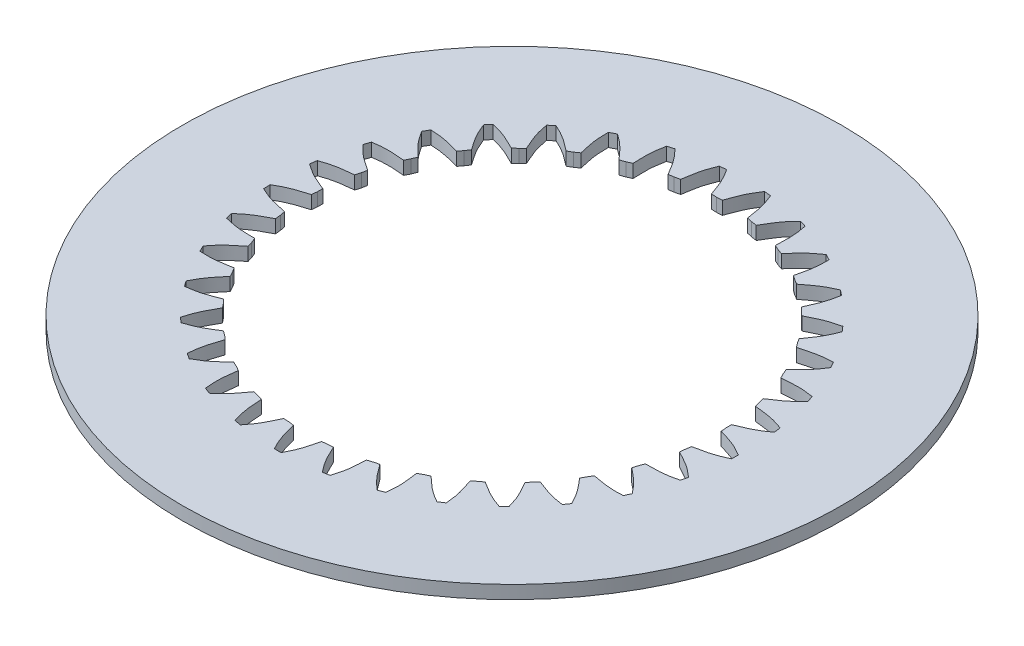
from build123d import *

# Parameters (mm, degrees)
ESBO_O1_R                = 100
RESSALTO_EXTRUS_O2_DEPTH = 4


with BuildPart() as part:
    # Esboço1 → Ressalto-extrusão2 (new body)
    with BuildSketch(Plane(origin=(0, 0, 0), x_dir=(1, 0, 0), z_dir=(0, 1, 0))):
        Circle(ESBO_O1_R)
        with BuildLine():
            Line((-38.387721765, -48.813954903), (-37.138830837, -49.877121184))
            add(Edge.make_bspline(
                [(-37.138830837, -49.877121184), (-37.389257811, -50.639614404), (-37.896831371, -52.159446189), (-38.85822142, -55.240347063), (-39.175718828, -57.647910799), (-39.300932619, -59.251706435)],
                knots=[-0.00620181, -0.00620181, -0.00620181, -0.00620181, 0.243606483, 0.493414777, 0.993031363, 0.993031363, 0.993031363, 0.993031363], degree=3))
            Line((-39.300932619, -59.251706435), (-37.571055603, -60.36343099))
            add(Edge.make_bspline(
                [(-37.571055603, -60.36343099), (-36.164207493, -59.58329169), (-34.106103478, -58.294348136), (-31.702993147, -56.139984667), (-30.531359153, -55.046918653), (-29.941801975, -54.502371219)],
                knots=[-0.006201811, -0.006201811, -0.006201811, -0.006201811, 0.493414776, 0.74322307, 0.993031363, 0.993031363, 0.993031363, 0.993031363], degree=3))
            Line((-29.941801975, -54.502371219), (-28.455903916, -55.196747259))
            Line((-28.455903916, -55.196747259), (-27.028376532, -56.004346577))
            add(Edge.make_bspline(
                [(-27.028376532, -56.004346577), (-27.129975174, -56.800454168), (-27.340746162, -58.38887954), (-27.701698316, -61.596048785), (-27.557823699, -64.020191487), (-27.377254395, -65.618701313)],
                knots=[-0.00620181, -0.00620181, -0.00620181, -0.00620181, 0.243606483, 0.493414777, 0.993031363, 0.993031363, 0.993031363, 0.993031363], degree=3))
            Line((-27.377254395, -65.618701313), (-25.468243254, -66.382954179))
            add(Edge.make_bspline(
                [(-25.468243254, -66.382954179), (-24.234461056, -65.350665257), (-22.457483833, -63.695515847), (-20.505516803, -61.125292911), (-19.561919865, -59.830246833), (-19.086073033, -59.18396565)],
                knots=[-0.006201811, -0.006201811, -0.006201811, -0.006201811, 0.493414776, 0.74322307, 0.993031363, 0.993031363, 0.993031363, 0.993031363], degree=3))
            Line((-19.086073033, -59.18396565), (-17.495615558, -59.584585354))
            Line((-17.495615558, -59.584585354), (-15.941046278, -60.107428968))
            add(Edge.make_bspline(
                [(-15.941046278, -60.107428968), (-15.890144547, -60.908377526), (-15.796495152, -62.507986654), (-15.543963659, -65.725508818), (-14.943917021, -68.078615652), (-14.464090866, -69.614065357)],
                knots=[-0.00620181, -0.00620181, -0.00620181, -0.00620181, 0.243606483, 0.493414777, 0.993031363, 0.993031363, 0.993031363, 0.993031363], degree=3))
            Line((-14.464090866, -69.614065357), (-12.444942238, -70.003224445))
            add(Edge.make_bspline(
                [(-12.444942238, -70.003224445), (-11.428818054, -68.756095512), (-9.997192209, -66.794561657), (-8.566917656, -63.901373809), (-7.885461826, -62.451154006), (-7.540523684, -61.726497361)],
                knots=[-0.006201811, -0.006201811, -0.006201811, -0.006201811, 0.493414776, 0.74322307, 0.993031363, 0.993031363, 0.993031363, 0.993031363], degree=3))
            Line((-7.540523684, -61.726497361), (-5.90299007, -61.818881289))
            Line((-5.90299007, -61.818881289), (-4.277565078, -62.038072266))
            add(Edge.make_bspline(
                [(-4.277565078, -62.038072266), (-4.076002696, -62.814913426), (-3.681317649, -64.367892268), (-2.824429656, -67.479477715), (-1.789898246, -69.676501271), (-1.028157407, -71.093395703)],
                knots=[-0.00620181, -0.00620181, -0.00620181, -0.00620181, 0.243606483, 0.493414777, 0.993031363, 0.993031363, 0.993031363, 0.993031363], degree=3))
            Line((-1.028157407, -71.093395703), (1.028151417, -71.093395703))
            add(Edge.make_bspline(
                [(1.028151417, -71.093395703), (1.78989221, -69.676501248), (2.824423988, -67.479477893), (3.681312216, -64.367892479), (4.07599735, -62.814913673), (4.277559838, -62.038072546)],
                knots=[-0.006201811, -0.006201811, -0.006201811, -0.006201811, 0.493414776, 0.74322307, 0.993031363, 0.993031363, 0.993031363, 0.993031363], degree=3))
            Line((4.277559838, -62.038072546), (5.90298486, -61.818881701))
            Line((5.90298486, -61.818881701), (7.54051847, -61.72649791))
            add(Edge.make_bspline(
                [(7.54051847, -61.72649791), (7.885456513, -62.451154606), (8.566912266, -63.901374461), (9.997186594, -66.794562386), (11.428812115, -68.756096508), (12.444936339, -70.00322541)],
                knots=[-0.00620181, -0.00620181, -0.00620181, -0.00620181, 0.243606483, 0.493414777, 0.993031363, 0.993031363, 0.993031363, 0.993031363], degree=3))
            Line((12.444936339, -70.00322541), (14.464085, -69.61406649))
            add(Edge.make_bspline(
                [(14.464085, -69.61406649), (14.943911106, -68.078616771), (15.543958143, -65.725510063), (15.796489873, -62.507987888), (15.890139361, -60.90837878), (15.941041203, -60.107430232)],
                knots=[-0.006201811, -0.006201811, -0.006201811, -0.006201811, 0.493414776, 0.74322307, 0.993031363, 0.993031363, 0.993031363, 0.993031363], degree=3))
            Line((15.941041203, -60.107430232), (17.495610537, -59.584586743))
            Line((17.495610537, -59.584586743), (19.086068034, -59.183967174))
            add(Edge.make_bspline(
                [(19.086068034, -59.183967174), (19.561914778, -59.830248426), (20.50551165, -61.12529457), (22.457478472, -63.695517624), (24.234455429, -65.350667357), (25.468237661, -66.382956241)],
                knots=[-0.00620181, -0.00620181, -0.00620181, -0.00620181, 0.243606483, 0.493414777, 0.993031363, 0.993031363, 0.993031363, 0.993031363], degree=3))
            Line((25.468237661, -66.382956241), (27.377248865, -65.618703533))
            add(Edge.make_bspline(
                [(27.377248865, -65.618703533), (27.557818119, -64.020193704), (27.701693151, -61.596051051), (27.340741229, -58.388881749), (27.129970334, -56.800456379), (27.028371804, -56.004348778)],
                knots=[-0.006201811, -0.006201811, -0.006201811, -0.006201811, 0.493414776, 0.74322307, 0.993031363, 0.993031363, 0.993031363, 0.993031363], degree=3))
            Line((27.028371804, -56.004348778), (28.455899264, -55.196749571))
            Line((28.455899264, -55.196749571), (29.94179737, -54.502373659))
            add(Edge.make_bspline(
                [(29.94179737, -54.502373659), (30.531354475, -55.046921178), (31.702988416, -56.139987269), (34.106098567, -58.294350894), (36.164202381, -59.583294815), (37.571050517, -60.363434072)],
                knots=[-0.00620181, -0.00620181, -0.00620181, -0.00620181, 0.243606483, 0.493414777, 0.993031363, 0.993031363, 0.993031363, 0.993031363], degree=3))
            Line((37.571050517, -60.363434072), (39.300927626, -59.25170966))
            add(Edge.make_bspline(
                [(39.300927626, -59.25170966), (39.175713783, -57.647914029), (38.858216793, -55.240350264), (37.896826961, -52.15944929), (37.389253493, -50.63961749), (37.138826626, -49.877124238)],
                knots=[-0.006201811, -0.006201811, -0.006201811, -0.006201811, 0.493414776, 0.74322307, 0.993031363, 0.993031363, 0.993031363, 0.993031363], degree=3))
            Line((37.138826626, -49.877124238), (38.387717651, -48.813958053))
            Line((38.387717651, -48.813958053), (39.715352137, -47.850922353))
            add(Edge.make_bspline(
                [(39.715352137, -47.850922353), (40.397311473, -48.274054773), (41.75463658, -49.125634554), (44.522035397, -50.786274436), (46.786880835, -51.662426753), (48.315947717, -52.162220116)],
                knots=[-0.00620181, -0.00620181, -0.00620181, -0.00620181, 0.243606483, 0.493414777, 0.993031363, 0.993031363, 0.993031363, 0.993031363], degree=3))
            Line((48.315947717, -52.162220116), (49.804168465, -50.743204618))
            add(Edge.make_bspline(
                [(49.804168465, -50.743204618), (49.377697081, -49.192088539), (48.610303236, -46.888119288), (47.083222628, -44.04483843), (46.297191614, -42.648530881), (45.90698749, -41.947210472)],
                knots=[-0.006201811, -0.006201811, -0.006201811, -0.006201811, 0.493414776, 0.74322307, 0.993031363, 0.993031363, 0.993031363, 0.993031363], degree=3))
            Line((45.90698749, -41.947210472), (46.932103904, -40.666902904))
            Line((46.932103904, -40.666902904), (48.0534906, -39.470014035))
            add(Edge.make_bspline(
                [(48.0534906, -39.470014035), (48.803204379, -39.756438248), (50.297163387, -40.335753408), (53.328829866, -41.442649694), (55.718559513, -41.87434398), (57.314580681, -42.075727616)],
                knots=[-0.00620181, -0.00620181, -0.00620181, -0.00620181, 0.243606483, 0.493414777, 0.993031363, 0.993031363, 0.993031363, 0.993031363], degree=3))
            Line((57.314580681, -42.075727616), (58.507356892, -40.400707947))
            add(Edge.make_bspline(
                [(58.507356892, -40.400707947), (57.795041753, -38.958332797), (56.605486667, -36.841229511), (54.567907954, -34.338332348), (53.531828604, -33.116015243), (53.015950217, -32.501215223)],
                knots=[-0.006201811, -0.006201811, -0.006201811, -0.006201811, 0.493414776, 0.74322307, 0.993031363, 0.993031363, 0.993031363, 0.993031363], degree=3))
            Line((53.015950217, -32.501215223), (53.780241641, -31.050039925))
            Line((53.780241641, -31.050039925), (54.654850711, -29.662556569))
            add(Edge.make_bspline(
                [(54.654850711, -29.662556569), (55.445222324, -29.801920458), (57.021819662, -30.088033036), (60.208181477, -30.601179611), (62.636424277, -30.572813309), (64.241715367, -30.468508689)],
                knots=[-0.00620181, -0.00620181, -0.00620181, -0.00620181, 0.243606483, 0.493414777, 0.993031363, 0.993031363, 0.993031363, 0.993031363], degree=3))
            Line((64.241715367, -30.468508689), (65.095937001, -28.598024426))
            add(Edge.make_bspline(
                [(65.095937001, -28.598024426), (64.123523033, -27.3165214), (62.554800326, -25.462801709), (60.080366912, -23.390749465), (58.831685832, -22.386600528), (58.208778371, -21.880541372)],
                knots=[-0.006201811, -0.006201811, -0.006201811, -0.006201811, 0.493414776, 0.74322307, 0.993031363, 0.993031363, 0.993031363, 0.993031363], degree=3))
            Line((58.208778371, -21.880541372), (58.684621322, -20.310947599))
            Line((58.684621322, -20.310947599), (59.280842116, -18.78301702))
            add(Edge.make_bspline(
                [(59.280842116, -18.78301702), (60.083305473, -18.770283611), (61.685558805, -18.752852754), (64.911452539, -18.653703163), (67.29044547, -18.166301506), (68.846987079, -17.76007847)],
                knots=[-0.00620181, -0.00620181, -0.00620181, -0.00620181, 0.243606483, 0.493414777, 0.993031363, 0.993031363, 0.993031363, 0.993031363], degree=3))
            Line((68.846987079, -17.76007847), (69.331780341, -15.761733787))
            add(Edge.make_bspline(
                [(69.331780341, -15.761733787), (68.134413118, -14.687419744), (66.243220516, -13.164081906), (63.421364872, -11.597763948), (62.00521265, -10.84807574), (61.297789613, -10.469047744)],
                knots=[-0.006201811, -0.006201811, -0.006201811, -0.006201811, 0.493414776, 0.74322307, 0.993031363, 0.993031363, 0.993031363, 0.993031363], degree=3))
            Line((61.297789613, -10.469047744), (61.467985888, -8.837764705))
            Line((61.467985888, -8.837764705), (61.764269431, -7.224610295))
            add(Edge.make_bspline(
                [(61.764269431, -7.224610295), (62.549821417, -7.060239805), (64.119821132, -6.739895511), (67.268654581, -6.032033279), (69.51241464, -5.103212232), (70.9639493, -4.409752738)],
                knots=[-0.00620181, -0.00620181, -0.00620181, -0.00620181, 0.243606483, 0.493414777, 0.993031363, 0.993031363, 0.993031363, 0.993031363], degree=3))
            Line((70.9639493, -4.409752738), (71.061792498, -2.355773104))
            add(Edge.make_bspline(
                [(71.061792498, -2.355773104), (69.682747991, -1.527476552), (67.537438122, -0.389577968), (64.470149463, 0.614394892), (62.93770953, 1.082526688), (62.171339029, 1.320824464)],
                knots=[-0.006201811, -0.006201811, -0.006201811, -0.006201811, 0.493414776, 0.74322307, 0.993031363, 0.993031363, 0.993031363, 0.993031363], degree=3))
            Line((62.171339029, 1.320824464), (62.02973729, 2.954837951))
            Line((62.02973729, 2.954837951), (62.015375125, 4.594912588))
            add(Edge.make_bspline(
                [(62.015375125, 4.594912588), (62.755623843, 4.90497938), (64.236626061, 5.516659035), (67.194592179, 6.807649923), (69.222024033, 8.144320347), (70.516089498, 9.099952865)],
                knots=[-0.00620181, -0.00620181, -0.00620181, -0.00620181, 0.243606483, 0.493414777, 0.993031363, 0.993031363, 0.993031363, 0.993031363], degree=3))
            Line((70.516089498, 9.099952865), (70.223446324, 11.135331441))
            add(Edge.make_bspline(
                [(70.223446324, 11.135331441), (68.712566795, 11.687673707), (66.390676747, 12.399006419), (63.188814876, 12.804347986), (61.595473605, 12.974003866), (60.797854267, 13.06295872)],
                knots=[-0.006201811, -0.006201811, -0.006201811, -0.006201811, 0.493414776, 0.74322307, 0.993031363, 0.993031363, 0.993031363, 0.993031363], degree=3))
            Line((60.797854267, 13.06295872), (60.34957237, 14.640645149))
            Line((60.34957237, 14.640645149), (60.025083581, 16.248363444))
            add(Edge.make_bspline(
                [(60.025083581, 16.248363444), (60.693274515, 16.692919915), (62.031751958, 17.573827235), (64.691942142, 19.401287005), (66.42976912, 21.097496054), (67.519594493, 22.280762546)],
                knots=[-0.00620181, -0.00620181, -0.00620181, -0.00620181, 0.243606483, 0.493414777, 0.993031363, 0.993031363, 0.993031363, 0.993031363], degree=3))
            Line((67.519594493, 22.280762546), (66.847041835, 24.223976096))
            add(Edge.make_bspline(
                [(66.847041835, 24.223976096), (65.258934406, 24.480400986), (62.844383334, 24.739458409), (59.623671883, 24.531518582), (58.027016778, 24.396566741), (57.226976643, 24.332963613)],
                knots=[-0.006201811, -0.006201811, -0.006201811, -0.006201811, 0.493414776, 0.74322307, 0.993031363, 0.993031363, 0.993031363, 0.993031363], degree=3))
            Line((57.226976643, 24.332963613), (56.488216665, 25.797301286))
            Line((56.488216665, 25.797301286), (55.865329123, 27.31455611))
            add(Edge.make_bspline(
                [(55.865329123, 27.31455611), (56.437312111, 27.877534832), (57.584888716, 28.995831531), (59.851156763, 31.293711024), (61.236569271, 33.288153284), (62.082765423, 34.656287418)],
                knots=[-0.00620181, -0.00620181, -0.00620181, -0.00620181, 0.243606483, 0.493414777, 0.993031363, 0.993031363, 0.993031363, 0.993031363], degree=3))
            Line((62.082765423, 34.656287418), (61.054611085, 36.43710314))
            add(Edge.make_bspline(
                [(61.054611085, 36.43710314), (59.446674097, 36.388342791), (57.026730169, 36.185761913), (53.903574041, 35.372056181), (52.361312377, 34.93737413), (51.587766981, 34.723511802)],
                knots=[-0.006201811, -0.006201811, -0.006201811, -0.006201811, 0.493414776, 0.74322307, 0.993031363, 0.993031363, 0.993031363, 0.993031363], degree=3))
            Line((51.587766981, 34.723511802), (50.585229631, 36.02157574))
            Line((50.585229631, 36.02157574), (49.686456115, 37.39352955))
            add(Edge.make_bspline(
                [(49.686456115, 37.39352955), (50.141558202, 38.054583006), (51.056757561, 39.369850927), (52.847194638, 42.055098792), (53.830120257, 44.275689923), (54.402103456, 45.779243766)],
                knots=[-0.00620181, -0.00620181, -0.00620181, -0.00620181, 0.243606483, 0.493414777, 0.993031363, 0.993031363, 0.993031363, 0.993031363], degree=3))
            Line((54.402103456, 45.779243766), (53.055507615, 47.33329834))
            add(Edge.make_bspline(
                [(53.055507615, 47.33329834), (51.485856099, 46.981115078), (49.147982394, 46.324217701), (46.235260588, 44.934155508), (44.80313372, 44.215453789), (44.084041009, 43.859061803)],
                knots=[-0.006201811, -0.006201811, -0.006201811, -0.006201811, 0.493414776, 0.74322307, 0.993031363, 0.993031363, 0.993031363, 0.993031363], degree=3))
            Line((44.084041009, 43.859061803), (42.853960599, 44.943936594))
            Line((42.853960599, 44.943936594), (41.711785127, 46.121003405))
            add(Edge.make_bspline(
                [(41.711785127, 46.121003405), (42.033557736, 46.8562394), (42.68330216, 48.320941334), (43.933197207, 51.296505717), (44.478110445, 53.66298777), (44.755207726, 55.247618967)],
                knots=[-0.00620181, -0.00620181, -0.00620181, -0.00620181, 0.243606483, 0.493414777, 0.993031363, 0.993031363, 0.993031363, 0.993031363], degree=3))
            Line((44.755207726, 55.247618967), (43.138839864, 56.518744812))
            add(Edge.make_bspline(
                [(43.138839864, 56.518744812), (41.664205117, 55.875867458), (39.492898481, 54.788395565), (36.895884352, 52.87221738), (35.625653078, 51.895471745), (34.987002936, 51.409431037)],
                knots=[-0.006201811, -0.006201811, -0.006201811, -0.006201811, 0.493414776, 0.74322307, 0.993031363, 0.993031363, 0.993031363, 0.993031363], degree=3))
            Line((34.987002936, 51.409431037), (33.573837777, 52.241906478))
            Line((33.573837777, 52.241906478), (32.229541544, 53.18154403))
            add(Edge.make_bspline(
                [(32.229541544, 53.18154403), (32.406354977, 53.964389219), (32.767161009, 55.525587022), (33.431339562, 58.683923273), (33.518545834, 61.11076542), (33.490742181, 62.719201273)],
                knots=[-0.00620181, -0.00620181, -0.00620181, -0.00620181, 0.243606483, 0.493414777, 0.993031363, 0.993031363, 0.993031363, 0.993031363], degree=3))
            Line((33.490742181, 62.719201273), (31.663022044, 63.661456589))
            add(Edge.make_bspline(
                [(31.663022044, 63.661456589), (30.336701207, 62.751120405), (28.410438319, 61.272378063), (26.222994725, 58.899339559), (25.160568511, 57.699852141), (24.625443418, 57.101729487)],
                knots=[-0.006201811, -0.006201811, -0.006201811, -0.006201811, 0.493414776, 0.74322307, 0.993031363, 0.993031363, 0.993031363, 0.993031363], degree=3))
            Line((24.625443418, 57.101729487), (23.080268982, 57.651717748))
            Line((23.080268982, 57.651717748), (21.582438357, 58.31996509))
            add(Edge.make_bspline(
                [(21.582438357, 58.31996509), (21.607902114, 59.122125409), (21.666729285, 60.723393324), (21.7211862, 63.950350942), (21.347533646, 66.349840786), (21.015833954, 67.923948232)],
                knots=[-0.00620181, -0.00620181, -0.00620181, -0.00620181, 0.243606483, 0.493414777, 0.993031363, 0.993031363, 0.993031363, 0.993031363], degree=3))
            Line((21.015833954, 67.923948232), (19.04282011, 68.503277456))
            add(Edge.make_bspline(
                [(19.04282011, 68.503277456), (17.912749874, 67.358384364), (16.301150894, 65.541817175), (14.602337746, 62.797686145), (13.786115444, 61.418809545), (13.373856215, 60.730222656)],
                knots=[-0.006201811, -0.006201811, -0.006201811, -0.006201811, 0.493414776, 0.74322307, 0.993031363, 0.993031363, 0.993031363, 0.993031363], degree=3))
            Line((13.373856215, 60.730222656), (11.75251913, 60.977845728))
            Line((11.75251913, 60.977845728), (10.155289616, 61.350550661))
            add(Edge.make_bspline(
                [(10.155289616, 61.350550661), (10.028483371, 62.143033945), (9.783205512, 63.726497978), (9.225972576, 66.905446307), (8.404965971, 69.190860033), (7.781358731, 70.673746727)],
                knots=[-0.00620181, -0.00620181, -0.00620181, -0.00620181, 0.243606483, 0.493414777, 0.993031363, 0.993031363, 0.993031363, 0.993031363], degree=3))
            Line((7.781358731, 70.673746727), (5.734361041, 70.869211393))
            add(Edge.make_bspline(
                [(5.734361041, 70.869211393), (4.841385089, 69.531140812), (3.602697404, 67.442404246), (2.453914234, 64.426360736), (1.913396244, 62.917931146), (1.638903002, 62.163767348)],
                knots=[-0.006201811, -0.006201811, -0.006201811, -0.006201811, 0.493414776, 0.74322307, 0.993031363, 0.993031363, 0.993031363, 0.993031363], degree=3))
            Line((1.638903002, 62.163767348), (2.617e-06, 62.100075488))
            Line((2.617e-06, 62.100075488), (-1.638897752, 62.163767483))
            add(Edge.make_bspline(
                [(-1.638897752, 62.163767483), (-1.913390891, 62.917931323), (-2.453908798, 64.426360958), (-3.602691736, 67.442404523), (-4.841379074, 69.531141324), (-5.73435507, 70.869211877)],
                knots=[-0.00620181, -0.00620181, -0.00620181, -0.00620181, 0.243606483, 0.493414777, 0.993031363, 0.993031363, 0.993031363, 0.993031363], degree=3))
            Line((-5.73435507, 70.869211877), (-7.781352776, 70.673747382))
            add(Edge.make_bspline(
                [(-7.781352776, 70.673747382), (-8.404959967, 69.190860669), (-9.225966958, 66.905447108), (-9.783200132, 63.72649879), (-10.02847808, 62.143034785), (-10.155284435, 61.350551521)],
                knots=[-0.006201811, -0.006201811, -0.006201811, -0.006201811, 0.493414776, 0.74322307, 0.993031363, 0.993031363, 0.993031363, 0.993031363], degree=3))
            Line((-10.155284435, 61.350551521), (-11.752513992, 60.977846719))
            Line((-11.752513992, 60.977846719), (-13.373851085, 60.730223783))
            add(Edge.make_bspline(
                [(-13.373851085, 60.730223783), (-13.78611022, 61.418810731), (-14.60233245, 62.797687391), (-16.301145381, 65.541818519), (-17.912744064, 67.358386005), (-19.042814338, 68.503279062)],
                knots=[-0.00620181, -0.00620181, -0.00620181, -0.00620181, 0.243606483, 0.493414777, 0.993031363, 0.993031363, 0.993031363, 0.993031363], degree=3))
            Line((-19.042814338, 68.503279062), (-21.01582823, 67.923950001))
            add(Edge.make_bspline(
                [(-21.01582823, 67.923950001), (-21.347527871, 66.349842547), (-21.721180836, 63.950352791), (-21.666724156, 60.723395139), (-21.607897078, 59.122127235), (-21.582433433, 58.319966916)],
                knots=[-0.006201811, -0.006201811, -0.006201811, -0.006201811, 0.493414776, 0.74322307, 0.993031363, 0.993031363, 0.993031363, 0.993031363], degree=3))
            Line((-21.582433433, 58.319966916), (-23.080264123, 57.651719693))
            Line((-23.080264123, 57.651719693), (-24.625438594, 57.101731564))
            add(Edge.make_bspline(
                [(-24.625438594, 57.101731564), (-25.160563607, 57.699854295), (-26.222989761, 58.899341785), (-28.410433161, 61.272380427), (-30.336695813, 62.751123116), (-31.66301668, 63.661459258)],
                knots=[-0.00620181, -0.00620181, -0.00620181, -0.00620181, 0.243606483, 0.493414777, 0.993031363, 0.993031363, 0.993031363, 0.993031363], degree=3))
            Line((-31.66301668, 63.661459258), (-33.490736895, 62.719204094))
            add(Edge.make_bspline(
                [(-33.490736895, 62.719204094), (-33.518540498, 61.110768242), (-33.431334644, 58.683926104), (-32.767156316, 55.525589774), (-32.406350377, 53.964391965), (-32.229537054, 53.181546754)],
                knots=[-0.006201811, -0.006201811, -0.006201811, -0.006201811, 0.493414776, 0.74322307, 0.993031363, 0.993031363, 0.993031363, 0.993031363], degree=3))
            Line((-32.229537054, 53.181546754), (-33.573833374, 52.241909308))
            Line((-33.573833374, 52.241909308), (-34.986998592, 51.409433989))
            add(Edge.make_bspline(
                [(-34.986998592, 51.409433989), (-35.625648669, 51.895474789), (-36.895879899, 52.872220505), (-39.492893863, 54.788398862), (-41.664200333, 55.87587114), (-43.138835103, 56.518748448)],
                knots=[-0.00620181, -0.00620181, -0.00620181, -0.00620181, 0.243606483, 0.493414777, 0.993031363, 0.993031363, 0.993031363, 0.993031363], degree=3))
            Line((-43.138835103, 56.518748448), (-44.75520307, 55.247622737))
            add(Edge.make_bspline(
                [(-44.75520307, 55.247622737), (-44.478105739, 53.66299155), (-43.933192914, 51.296509427), (-42.683298073, 48.320944925), (-42.033553739, 46.856242967), (-41.711781233, 46.12100693)],
                knots=[-0.006201811, -0.006201811, -0.006201811, -0.006201811, 0.493414776, 0.74322307, 0.993031363, 0.993031363, 0.993031363, 0.993031363], degree=3))
            Line((-41.711781233, 46.12100693), (-42.853956812, 44.943940205))
            Line((-42.853956812, 44.943940205), (-44.084037303, 43.859065524))
            add(Edge.make_bspline(
                [(-44.084037303, 43.859065524), (-44.803129967, 44.215457611), (-46.235256806, 44.934159419), (-49.147978483, 46.324221813), (-51.485852099, 46.981119599), (-53.055503627, 47.333302811)],
                knots=[-0.00620181, -0.00620181, -0.00620181, -0.00620181, 0.243606483, 0.493414777, 0.993031363, 0.993031363, 0.993031363, 0.993031363], degree=3))
            Line((-53.055503627, 47.333302811), (-54.402099597, 45.779248349))
            add(Edge.make_bspline(
                [(-54.402099597, 45.779248349), (-53.830116352, 44.275694526), (-52.847191125, 42.055103248), (-51.056754227, 39.369855227), (-50.141554952, 38.054587265), (-49.68645296, 37.393533749)],
                knots=[-0.006201811, -0.006201811, -0.006201811, -0.006201811, 0.493414776, 0.74322307, 0.993031363, 0.993031363, 0.993031363, 0.993031363], degree=3))
            Line((-49.68645296, 37.393533749), (-50.585226595, 36.021580003))
            Line((-50.585226595, 36.021580003), (-51.587764046, 34.723516157))
            add(Edge.make_bspline(
                [(-51.587764046, 34.723516157), (-52.361309415, 34.937378593), (-53.903571068, 35.372060737), (-57.026727107, 36.185766691), (-59.446671024, 36.388347987), (-61.054608016, 36.437108285)],
                knots=[-0.00620181, -0.00620181, -0.00620181, -0.00620181, 0.243606483, 0.493414777, 0.993031363, 0.993031363, 0.993031363, 0.993031363], degree=3))
            Line((-61.054608016, 36.437108285), (-62.082762502, 34.656292648))
            add(Edge.make_bspline(
                [(-62.082762502, 34.656292648), (-61.236566307, 33.288158543), (-59.851154157, 31.293716065), (-57.584886257, 28.995836384), (-56.437309726, 27.877539629), (-55.865326819, 27.314560829)],
                knots=[-0.006201811, -0.006201811, -0.006201811, -0.006201811, 0.493414776, 0.74322307, 0.993031363, 0.993031363, 0.993031363, 0.993031363], degree=3))
            Line((-55.865326819, 27.314560829), (-56.488214491, 25.797306046))
            Line((-56.488214491, 25.797306046), (-57.226974585, 24.332968445))
            add(Edge.make_bspline(
                [(-57.226974585, 24.332968445), (-58.027014714, 24.396571685), (-59.623669827, 24.531523619), (-62.844381232, 24.739463679), (-65.258932372, 24.48040667), (-66.847039795, 24.223981729)],
                knots=[-0.00620181, -0.00620181, -0.00620181, -0.00620181, 0.243606483, 0.493414777, 0.993031363, 0.993031363, 0.993031363, 0.993031363], degree=3))
            Line((-66.847039795, 24.223981729), (-67.519592614, 22.280768235))
            add(Edge.make_bspline(
                [(-67.519592614, 22.280768235), (-66.429767205, 21.097501779), (-64.691940537, 19.401292447), (-62.031750461, 17.573832466), (-60.693273081, 16.692925077), (-60.025082212, 16.248368514)],
                knots=[-0.006201811, -0.006201811, -0.006201811, -0.006201811, 0.493414776, 0.74322307, 0.993031363, 0.993031363, 0.993031363, 0.993031363], degree=3))
            Line((-60.025082212, 16.248368514), (-60.349571136, 14.640650235))
            Line((-60.349571136, 14.640650235), (-60.79785316, 13.062963854))
            add(Edge.make_bspline(
                [(-60.79785316, 13.062963854), (-61.595472514, 12.974009111), (-63.18881381, 12.804353321), (-66.39067568, 12.399011992), (-68.712565874, 11.687679673), (-70.223445387, 11.135337359)],
                knots=[-0.00620181, -0.00620181, -0.00620181, -0.00620181, 0.243606483, 0.493414777, 0.993031363, 0.993031363, 0.993031363, 0.993031363], degree=3))
            Line((-70.223445387, 11.135337359), (-70.516088729, 9.099958806))
            add(Edge.make_bspline(
                [(-70.516088729, 9.099958806), (-69.222023236, 8.144326331), (-67.194591633, 6.807655571), (-64.236625582, 5.516664454), (-62.755623412, 4.904984719), (-62.01537474, 4.594917826)],
                knots=[-0.006201811, -0.006201811, -0.006201811, -0.006201811, 0.493414776, 0.74322307, 0.993031363, 0.993031363, 0.993031363, 0.993031363], degree=3))
            Line((-62.01537474, 4.594917826), (-62.029737041, 2.954843178))
            Line((-62.029737041, 2.954843178), (-62.171338914, 1.320829715))
            add(Edge.make_bspline(
                [(-62.171338914, 1.320829715), (-62.937709452, 1.082532044), (-64.470149425, 0.614400333), (-67.537438129, -0.389572293), (-69.682748216, -1.52747052), (-71.061792698, -2.355767116)],
                knots=[-0.00620181, -0.00620181, -0.00620181, -0.00620181, 0.243606483, 0.493414777, 0.993031363, 0.993031363, 0.993031363, 0.993031363], degree=3))
            Line((-71.061792698, -2.355767116), (-70.96394967, -4.409746844))
            add(Edge.make_bspline(
                [(-70.96394967, -4.409746844), (-69.51241499, -5.10320629), (-67.268655113, -6.032027714), (-64.119821687, -6.739890184), (-62.549822004, -7.060234566), (-61.764270045, -7.224605164)],
                knots=[-0.006201811, -0.006201811, -0.006201811, -0.006201811, 0.493414776, 0.74322307, 0.993031363, 0.993031363, 0.993031363, 0.993031363], degree=3))
            Line((-61.764270045, -7.224605164), (-61.467986633, -8.83775961))
            Line((-61.467986633, -8.83775961), (-61.297790494, -10.469042652))
            add(Edge.make_bspline(
                [(-61.297790494, -10.469042652), (-62.005213587, -10.848070551), (-63.421365865, -11.597758684), (-66.243221597, -13.164076421), (-68.134414481, -14.687413948), (-69.331781671, -15.76172803)],
                knots=[-0.00620181, -0.00620181, -0.00620181, -0.00620181, 0.243606483, 0.493414777, 0.993031363, 0.993031363, 0.993031363, 0.993031363], degree=3))
            Line((-69.331781671, -15.76172803), (-68.846988574, -17.760072753))
            add(Edge.make_bspline(
                [(-68.846988574, -17.760072753), (-67.290446954, -18.16629574), (-64.911454131, -18.653697802), (-61.685560373, -18.75284763), (-60.083307058, -18.770278579), (-59.280843705, -18.7830121)],
                knots=[-0.006201811, -0.006201811, -0.006201811, -0.006201811, 0.493414776, 0.74322307, 0.993031363, 0.993031363, 0.993031363, 0.993031363], degree=3))
            Line((-59.280843705, -18.7830121), (-58.684623034, -20.310942739))
            Line((-58.684623034, -20.310942739), (-58.208780216, -21.88053654))
            add(Edge.make_bspline(
                [(-58.208780216, -21.88053654), (-58.83168775, -22.386595612), (-60.080368899, -23.390744485), (-62.554802442, -25.462796529), (-64.123525484, -27.316515968), (-65.095939412, -28.598019026)],
                knots=[-0.00620181, -0.00620181, -0.00620181, -0.00620181, 0.243606483, 0.493414777, 0.993031363, 0.993031363, 0.993031363, 0.993031363], degree=3))
            Line((-65.095939412, -28.598019026), (-64.241717933, -30.46850336))
            add(Edge.make_bspline(
                [(-64.241717933, -30.46850336), (-62.636426842, -30.57280793), (-60.208184071, -30.601174649), (-57.021822188, -30.088028303), (-55.445224848, -29.801915818), (-54.654853219, -29.66255204)],
                knots=[-0.006201811, -0.006201811, -0.006201811, -0.006201811, 0.493414776, 0.74322307, 0.993031363, 0.993031363, 0.993031363, 0.993031363], degree=3))
            Line((-54.654853219, -29.66255204), (-53.780244258, -31.050035478))
            Line((-53.780244258, -31.050035478), (-53.015952959, -32.501210829))
            add(Edge.make_bspline(
                [(-53.015952959, -32.501210829), (-53.531831434, -33.11601078), (-54.567910864, -34.338327836), (-56.605489741, -36.841224827), (-57.795045204, -38.958327929), (-58.507360297, -40.400703103)],
                knots=[-0.00620181, -0.00620181, -0.00620181, -0.00620181, 0.243606483, 0.493414777, 0.993031363, 0.993031363, 0.993031363, 0.993031363], degree=3))
            Line((-58.507360297, -40.400703103), (-57.314584225, -42.075722871))
            add(Edge.make_bspline(
                [(-57.314584225, -42.075722871), (-55.718563066, -41.874339184), (-53.328833368, -41.442645314), (-50.29716678, -40.33574924), (-48.803207752, -39.756434171), (-48.053493936, -39.470010064)],
                knots=[-0.006201811, -0.006201811, -0.006201811, -0.006201811, 0.493414776, 0.74322307, 0.993031363, 0.993031363, 0.993031363, 0.993031363], degree=3))
            Line((-48.053493936, -39.470010064), (-46.932107331, -40.666899034))
            Line((-46.932107331, -40.666899034), (-45.906991031, -41.947206677))
            add(Edge.make_bspline(
                [(-45.906991031, -41.947206677), (-46.297195254, -42.648527035), (-47.083226355, -44.044834552), (-48.610307157, -46.888115271), (-49.377701406, -49.192084413), (-49.804172741, -50.743200507)],
                knots=[-0.00620181, -0.00620181, -0.00620181, -0.00620181, 0.243606483, 0.493414777, 0.993031363, 0.993031363, 0.993031363, 0.993031363], degree=3))
            Line((-49.804172741, -50.743200507), (-48.315952112, -52.162216129))
            add(Edge.make_bspline(
                [(-48.315952112, -52.162216129), (-46.786885247, -51.662422718), (-44.52203968, -50.7862708), (-41.754640716, -49.125631105), (-40.397315572, -48.27405141), (-39.71535618, -47.850919086)],
                knots=[-0.006201811, -0.006201811, -0.006201811, -0.006201811, 0.493414776, 0.74322307, 0.993031363, 0.993031363, 0.993031363, 0.993031363], degree=3))
            Line((-39.71535618, -47.850919086), (-38.387721765, -48.813954903))
        make_face(mode=Mode.SUBTRACT)
    extrude(amount=RESSALTO_EXTRUS_O2_DEPTH)


solid = part.part
